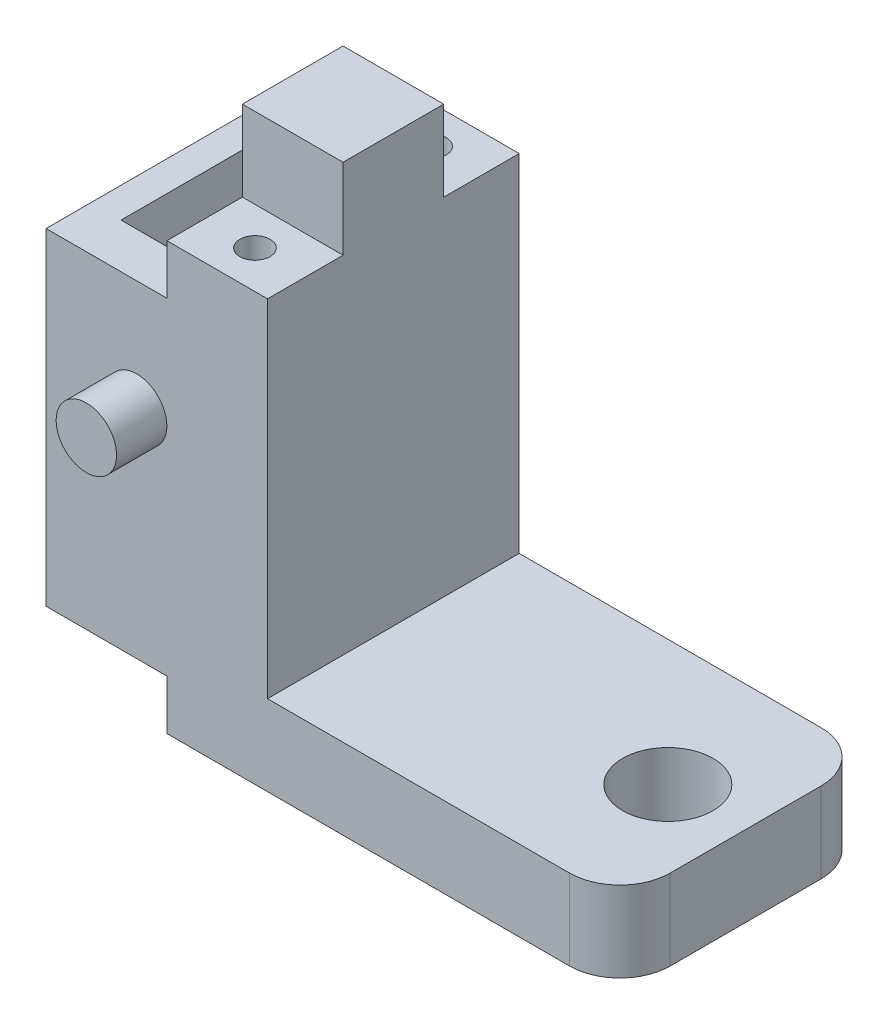
from build123d import *

# Parameters (mm, degrees)
SKETCH1_R           = 4.5
BOSS_EXTRUDE1_DEPTH = 8
SKETCH2_W           = 10
SKETCH2_H           = 25
BOSS_EXTRUDE2_DEPTH = 34.4
SKETCH5_W           = 10
SKETCH5_H           = 10
BOSS_EXTRUDE4_DEPTH = 8
SKETCH6_R           = 1.5
CUT_EXTRUDE1_DEPTH  = 15
SKETCH10_W          = 25
SKETCH10_H          = 32.5
BOSS_EXTRUDE6_DEPTH = 12
SKETCH12_W          = 12
SKETCH12_H          = 21.5
CUT_EXTRUDE3_DEPTH  = 21.5
SKETCH13_R          = 1
CUT_EXTRUDE4_DEPTH  = 10
SKETCH14_W          = 9
SKETCH14_H          = 13
CUT_EXTRUDE5_DEPTH  = 38.45
CUT_EXTRUDE6_REACH  = 59
SKETCH15_W          = 15
SKETCH15_H          = 20.5
SKETCH16_R          = 3
BOSS_EXTRUDE7_DEPTH = 5


with BuildPart() as part:
    # Sketch1 → Boss-Extrude1 (new body)
    with BuildSketch(Plane(origin=(0, 0, 0), x_dir=(1, 0, 0), z_dir=(0, 1, 0))):
        with BuildLine():
            Line((0, 0), (40, 0))
            ThreePointArc((40, 0), (43.535533906, 1.464466094), (45, 5))
            Line((45, 5), (45, 20))
            ThreePointArc((45, 20), (43.535533906, 23.535533906), (40, 25))
            Line((40, 25), (0, 25))
            Line((0, 25), (0, 0))
        make_face()
        with Locations((37.263316161, 12.5)):
            Circle(SKETCH1_R, mode=Mode.SUBTRACT)
    extrude(amount=BOSS_EXTRUDE1_DEPTH)

    # Sketch2 → Boss-Extrude2 (add)
    with BuildSketch(Plane(origin=(0, 8, 0), x_dir=(1, 0, 0), z_dir=(0, 1, 0))):
        with Locations((5, 12.5)):
            Rectangle(SKETCH2_W, SKETCH2_H)
    extrude(amount=BOSS_EXTRUDE2_DEPTH)

    # Sketch5 → Boss-Extrude4 (add)
    with BuildSketch(Plane(origin=(0, 42.4, 0), x_dir=(1, 0, 0), z_dir=(0, 1, 0))):
        with Locations((5, 12.5)):
            Rectangle(SKETCH5_W, SKETCH5_H)
    extrude(amount=BOSS_EXTRUDE4_DEPTH)

    # Sketch6 → Cut-Extrude1 (cut)
    with BuildSketch(Plane(origin=(0, 42.4, 0), x_dir=(1, 0, 0), z_dir=(0, 1, 0))):
        with Locations((5, 21.25)):
            Circle(SKETCH6_R)
        with Locations((5, 3.75)):
            Circle(SKETCH6_R)
    extrude(amount=-CUT_EXTRUDE1_DEPTH, mode=Mode.SUBTRACT)

    # Sketch10 → Boss-Extrude6 (add)
    with BuildSketch(Plane.ZY):
        with Locations((-12.5, 21.2)):
            Rectangle(SKETCH10_W, SKETCH10_H)
    extrude(amount=BOSS_EXTRUDE6_DEPTH)

    # Sketch12 → Cut-Extrude3 (cut)
    with BuildSketch(Plane(origin=(0, 0, -25), x_dir=(-1, 0, 0), z_dir=(0, 0, -1))):
        with Locations((3, 21.2)):
            Rectangle(SKETCH12_W, SKETCH12_H)
    extrude(amount=-CUT_EXTRUDE3_DEPTH, mode=Mode.SUBTRACT)

    # Sketch13 → Cut-Extrude4 (cut)
    with BuildSketch(Plane(origin=(0, 0, -25), x_dir=(-1, 0, 0), z_dir=(0, 0, -1))):
        with Locations((3, 35.2)):
            Circle(SKETCH13_R)
        with Locations((3, 7.2)):
            Circle(SKETCH13_R)
    extrude(amount=-CUT_EXTRUDE4_DEPTH, mode=Mode.SUBTRACT)

    # Sketch14 → Cut-Extrude5 (cut, through all)
    with BuildSketch(Plane(origin=(0, 37.45, 0), x_dir=(1, 0, 0), z_dir=(0, 1, 0))):
        with Locations((-4.5, 10.945919096)):
            Rectangle(SKETCH14_W, SKETCH14_H)
    extrude(amount=-CUT_EXTRUDE5_DEPTH, mode=Mode.SUBTRACT)

    # Sketch15 → Cut-Extrude6 (cut, up to next)
    with BuildSketch(Plane.ZY.offset(12), mode=Mode.PRIVATE) as cut_extrude6_sk1:
        with Locations((-12.5, 21.2)):
            Rectangle(SKETCH15_W, SKETCH15_H)
    cut_extrude6_tool1 = extrude(cut_extrude6_sk1.sketch, amount=-CUT_EXTRUDE6_REACH, mode=Mode.PRIVATE) & part.part
    add(cut_extrude6_tool1.solids().sort_by_distance((-12, 21.2, -12.5))[0], mode=Mode.SUBTRACT)

    # Sketch16 → Boss-Extrude7 (add)
    with BuildSketch(Plane.XY):
        with Locations((-3, 26.45)):
            Circle(SKETCH16_R)
    extrude(amount=BOSS_EXTRUDE7_DEPTH)


solid = part.part
